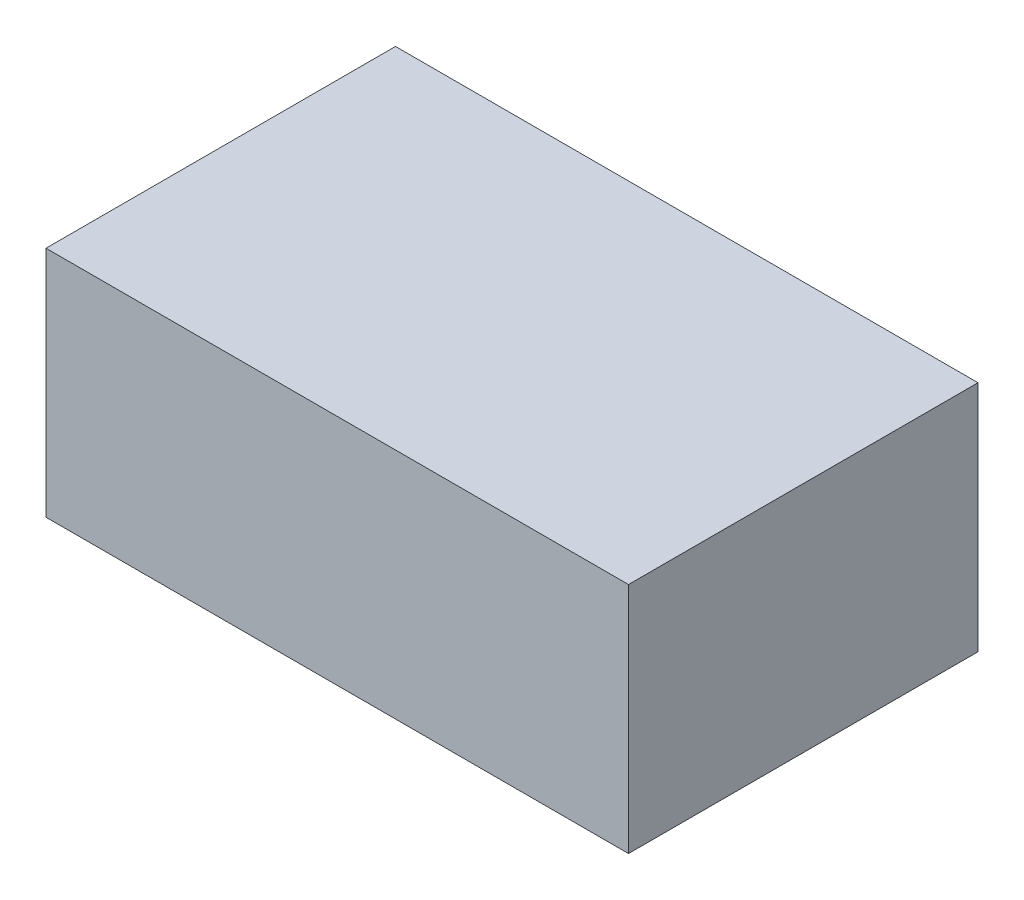
from build123d import *

# Parameters (mm, degrees)
SKETCH1_W           = 60
SKETCH1_H           = 36
BOSS_EXTRUDE1_DEPTH = 24


with BuildPart() as part:
    # Sketch1 → Boss-Extrude1 (new body)
    with BuildSketch(Plane(origin=(0, 0, 0), x_dir=(1, 0, 0), z_dir=(0, 1, 0))):
        Rectangle(SKETCH1_W, SKETCH1_H)
    extrude(amount=-BOSS_EXTRUDE1_DEPTH)


solid = part.part
